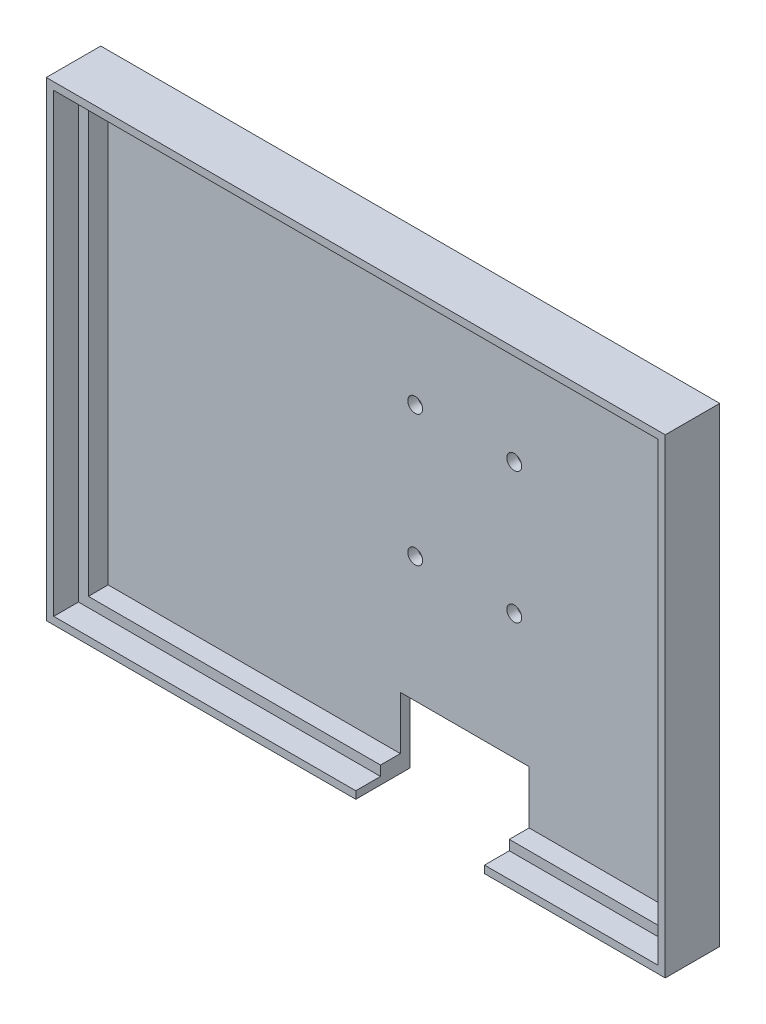
from build123d import *

# Parameters (mm, degrees)
SKETCH1_W           = 125
SKETCH1_H           = 95
SKETCH1_W_2         = 118
SKETCH1_H_2         = 88
BOSS_EXTRUDE1_DEPTH = 4
SKETCH2_W           = 125
SKETCH2_H           = 95
BOSS_EXTRUDE2_DEPTH = 2
SKETCH3_W           = 125
SKETCH3_H           = 95
SKETCH3_W_2         = 122
SKETCH3_H_2         = 92
BOSS_EXTRUDE3_DEPTH = 5
SKETCH5_R           = 1.5
CUT_EXTRUDE1_DEPTH  = 26.5
SKETCH7_W           = 26
SKETCH7_H           = 14.212575567
CUT_EXTRUDE2_DEPTH  = 26.5


with BuildPart() as part:
    # Sketch1 → Boss-Extrude1 (new body)
    with BuildSketch(Plane.XY):
        Rectangle(SKETCH1_W, SKETCH1_H)
        Rectangle(SKETCH1_W_2, SKETCH1_H_2, mode=Mode.SUBTRACT)
    extrude(amount=BOSS_EXTRUDE1_DEPTH)

    # Sketch2 → Boss-Extrude2 (add)
    with BuildSketch(Plane(origin=(0, 0, 0), x_dir=(-1, 0, 0), z_dir=(0, 0, -1))):
        Rectangle(SKETCH2_W, SKETCH2_H)
    extrude(amount=BOSS_EXTRUDE2_DEPTH)

    # Sketch3 → Boss-Extrude3 (add)
    with BuildSketch(Plane.XY.offset(4)):
        Rectangle(SKETCH3_W, SKETCH3_H)
        Rectangle(SKETCH3_W_2, SKETCH3_H_2, mode=Mode.SUBTRACT)
    extrude(amount=BOSS_EXTRUDE3_DEPTH)

    # Sketch5 → Cut-Extrude1 (cut)
    with BuildSketch(Plane(origin=(0, 0, -2), x_dir=(-1, 0, 0), z_dir=(0, 0, -1))):
        with Locations((-23, 18.5)):
            Circle(SKETCH5_R)
        with Locations((-23, -8)):
            Circle(SKETCH5_R)
        with Locations((-3, -8)):
            Circle(SKETCH5_R)
        with Locations((-3, 18.5)):
            Circle(SKETCH5_R)
    extrude(amount=-CUT_EXTRUDE1_DEPTH, mode=Mode.SUBTRACT)

    # Sketch7 → Cut-Extrude2 (cut)
    with BuildSketch(Plane(origin=(0, 0, -2), x_dir=(-1, 0, 0), z_dir=(0, 0, -1))):
        with Locations((-13, -40.393712217)):
            Rectangle(SKETCH7_W, SKETCH7_H)
    extrude(amount=-CUT_EXTRUDE2_DEPTH, mode=Mode.SUBTRACT)


solid = part.part
